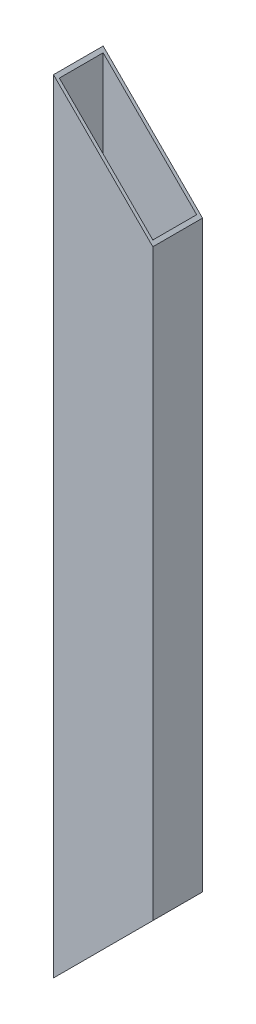
from build123d import *

# Parameters (mm, degrees)
CROQUIS1_W              = 50.8
CROQUIS1_H              = 25.4
CROQUIS1_W_2            = 47.8
CROQUIS1_H_2            = 22.4
SALIENTE_EXTRUIR1_DEPTH = 400
CORTAR_EXTRUIR1_DEPTH   = 26


with BuildPart() as part:
    # Croquis1 → Saliente-Extruir1 (new body)
    with BuildSketch(Plane(origin=(0, 0, 0), x_dir=(1, 0, 0), z_dir=(0, 1, 0))):
        Rectangle(CROQUIS1_W, CROQUIS1_H)
        Rectangle(CROQUIS1_W_2, CROQUIS1_H_2, mode=Mode.SUBTRACT)
    extrude(amount=SALIENTE_EXTRUIR1_DEPTH)

    # Croquis2 → Cortar-Extruir1 (cut)
    with BuildSketch(Plane.XY.offset(12.7)):
        Polygon((-25.4, 0), (25.4, 50.8), (25.4, 0), align=None)
        Polygon((25.4, 400), (-25.4, 400), (25.4, 349.2), align=None)
    extrude(amount=-CORTAR_EXTRUIR1_DEPTH, mode=Mode.SUBTRACT)


solid = part.part
